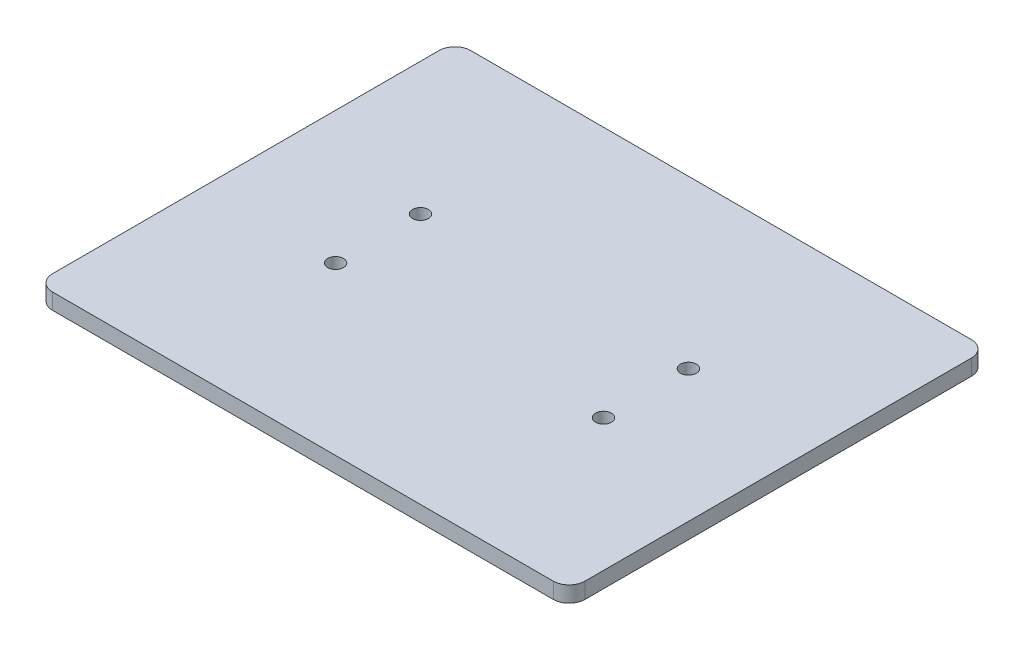
from build123d import *

# Parameters (mm, degrees)
SKETCH_1_W          = 167.75
SKETCH_1_H          = 131.75
EXTRUDE_1_DEPTH     = 5
FILLET_1_R          = 5
FILLET_2_R          = 5
FILLET_3_R          = 5
FILLET_4_R          = 5
SKETCH_2_R          = 2.5
CUT_EXTRUDE_1_DEPTH = 10


with BuildPart() as part:
    # Эскиз1 → Бобышка-Вытянуть1 (new body)
    with BuildSketch(Plane(origin=(0, 0, 0), x_dir=(1, 0, 0), z_dir=(0, 1, 0))):
        with Locations((83.875, 65.875)):
            Rectangle(SKETCH_1_W, SKETCH_1_H)
    extrude(amount=EXTRUDE_1_DEPTH)

    # Скругление1
    fillet_1_edges = [part.edges().sort_by_distance(p)[0] for p in [
        (0, 2.5, 0),
    ]]
    fillet(fillet_1_edges, radius=FILLET_1_R)

    # Скругление2
    fillet_2_edges = [part.edges().sort_by_distance(p)[0] for p in [
        (0, 2.5, -131.75),
    ]]
    fillet(fillet_2_edges, radius=FILLET_2_R)

    # Скругление3
    fillet_3_edges = [part.edges().sort_by_distance(p)[0] for p in [
        (167.75, 2.5, -131.75),
    ]]
    fillet(fillet_3_edges, radius=FILLET_3_R)

    # Скругление4
    fillet_4_edges = [part.edges().sort_by_distance(p)[0] for p in [
        (167.75, 2.5, 0),
    ]]
    fillet(fillet_4_edges, radius=FILLET_4_R)

    # Эскиз2 → Вырез-Вытянуть1 (cut)
    with BuildSketch(Plane(origin=(0, 5, 0), x_dir=(1, 0, 0), z_dir=(0, 1, 0))):
        with Locations((126.075, 79.25)):
            Circle(SKETCH_2_R)
        with Locations((126.075, 52.5)):
            Circle(SKETCH_2_R)
        with Locations((41.675, 79.25)):
            Circle(SKETCH_2_R)
        with Locations((41.675, 52.5)):
            Circle(SKETCH_2_R)
    extrude(amount=-CUT_EXTRUDE_1_DEPTH, mode=Mode.SUBTRACT)


solid = part.part
